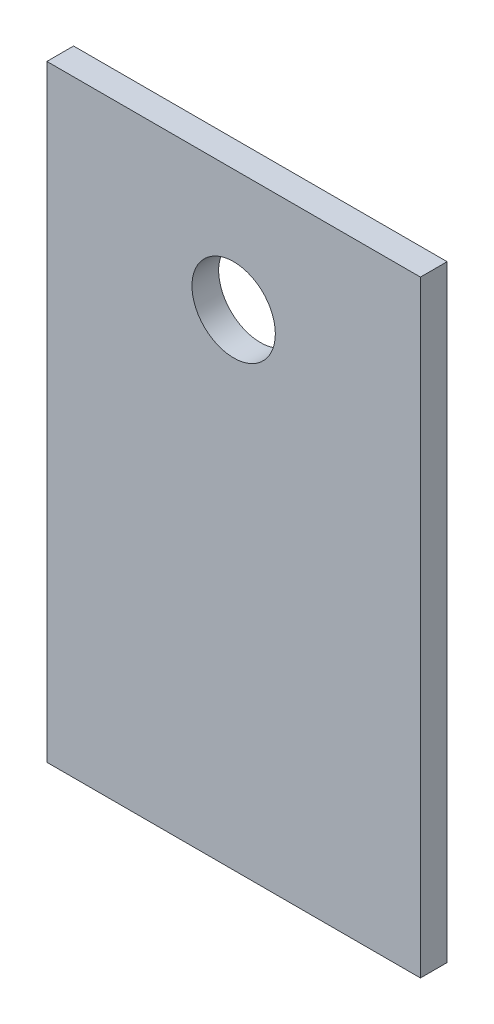
from build123d import *

# Parameters (mm, degrees)
SKETCH1_W           = 224
SKETCH1_H           = 364
BOSS_EXTRUDE1_DEPTH = 16
SKETCH2_R           = 25
CUT_EXTRUDE1_DEPTH  = 17


with BuildPart() as part:
    # Sketch1 → Boss-Extrude1 (new body)
    with BuildSketch(Plane.XY):
        Rectangle(SKETCH1_W, SKETCH1_H)
    extrude(amount=BOSS_EXTRUDE1_DEPTH)

    # Sketch2 → Cut-Extrude1 (cut, through all)
    with BuildSketch(Plane.XY.offset(16)):
        with Locations((0, 109)):
            Circle(SKETCH2_R)
    extrude(amount=-CUT_EXTRUDE1_DEPTH, mode=Mode.SUBTRACT)


solid = part.part
